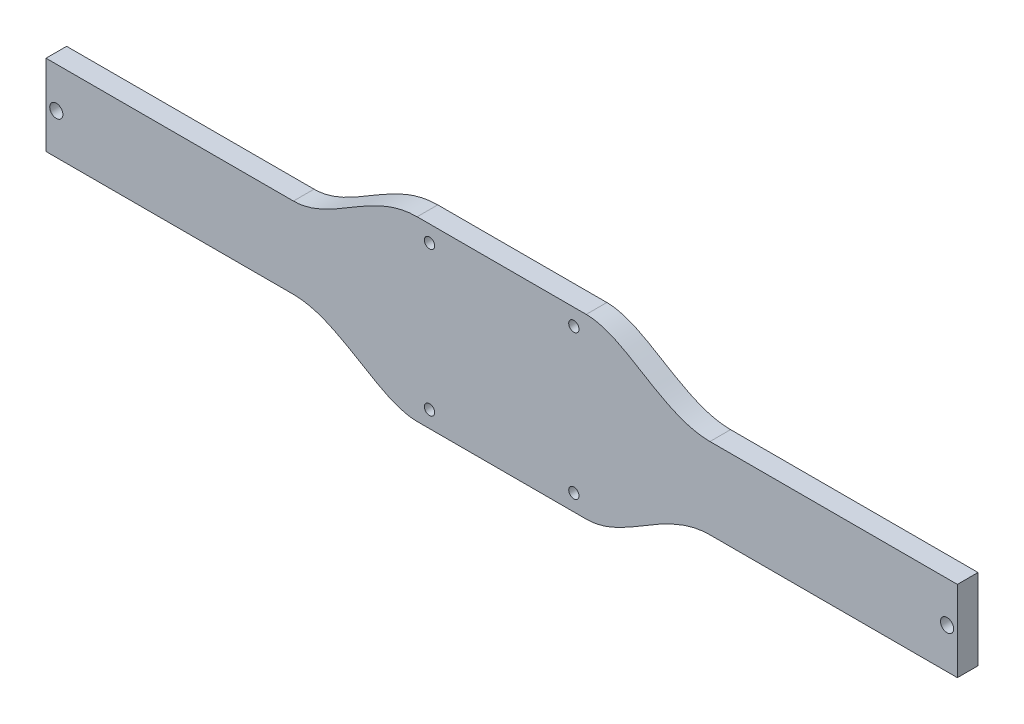
from build123d import *

# Parameters (mm, degrees)
SKETCH1_R      = 1.5875
SKETCH1_R_2    = 2.032
EXTRUDE1_DEPTH = 6.35


with BuildPart() as part:
    # Sketch1 → Extrude1 (new body)
    with BuildSketch(Plane.XY):
        with BuildLine():
            Line((-198.340264606, 29.708721685), (-122.140264606, 29.708721685))
            add(Edge.make_bspline(
                [(-84.040264606, 44.567721685), (-98.359806002, 44.567721685), (-110.19434592, 29.708721685), (-122.140264606, 29.708721685)],
                knots=[0, 0, 0, 0, 1, 1, 1, 1], degree=3))
            Line((-84.040264606, 44.567721685), (-31.970264606, 44.567721685))
            add(Edge.make_bspline(
                [(-31.970264606, 44.567721685), (-19.845994983, 44.567721685), (-8.482470496, 29.708721685), (6.129735394, 29.708721685)],
                knots=[0, 0, 0, 0, 1, 1, 1, 1], degree=3))
            Line((6.129735394, 29.708721685), (82.329735394, 29.708721685))
            Line((82.329735394, 29.708721685), (82.329735394, 4.816721685))
            Line((82.329735394, 4.816721685), (6.129735394, 4.816721685))
            add(Edge.make_bspline(
                [(-31.970264606, -10.042278315), (-19.845994974, -10.042278315), (-8.148130117, 4.816721685), (6.129735394, 4.816721685)],
                knots=[0, 0, 0, 0, 1, 1, 1, 1], degree=3))
            Line((-31.970264606, -10.042278315), (-84.040264606, -10.042278315))
            add(Edge.make_bspline(
                [(-84.040264606, -10.042278315), (-95.986183291, -10.042278315), (-107.820723209, 4.816721685), (-122.140264606, 4.816721685)],
                knots=[0, 0, 0, 0, 1, 1, 1, 1], degree=3))
            Line((-122.140264606, 4.816721685), (-198.340264606, 4.816721685))
            Line((-198.340264606, 4.816721685), (-198.340264606, 29.708721685))
        make_face()
        with Locations((-80.230264606, 39.487721685)):
            Circle(SKETCH1_R, mode=Mode.SUBTRACT)
        with Locations((-35.780264606, 39.487721685)):
            Circle(SKETCH1_R, mode=Mode.SUBTRACT)
        with Locations((-80.230264606, -4.962278315)):
            Circle(SKETCH1_R, mode=Mode.SUBTRACT)
        with Locations((-35.780264606, -4.962278315)):
            Circle(SKETCH1_R, mode=Mode.SUBTRACT)
        with Locations((79.154735394, 17.262721685)):
            Circle(SKETCH1_R_2, mode=Mode.SUBTRACT)
        with Locations((-195.165264606, 17.262721685)):
            Circle(SKETCH1_R_2, mode=Mode.SUBTRACT)
    extrude(amount=EXTRUDE1_DEPTH)


solid = part.part
